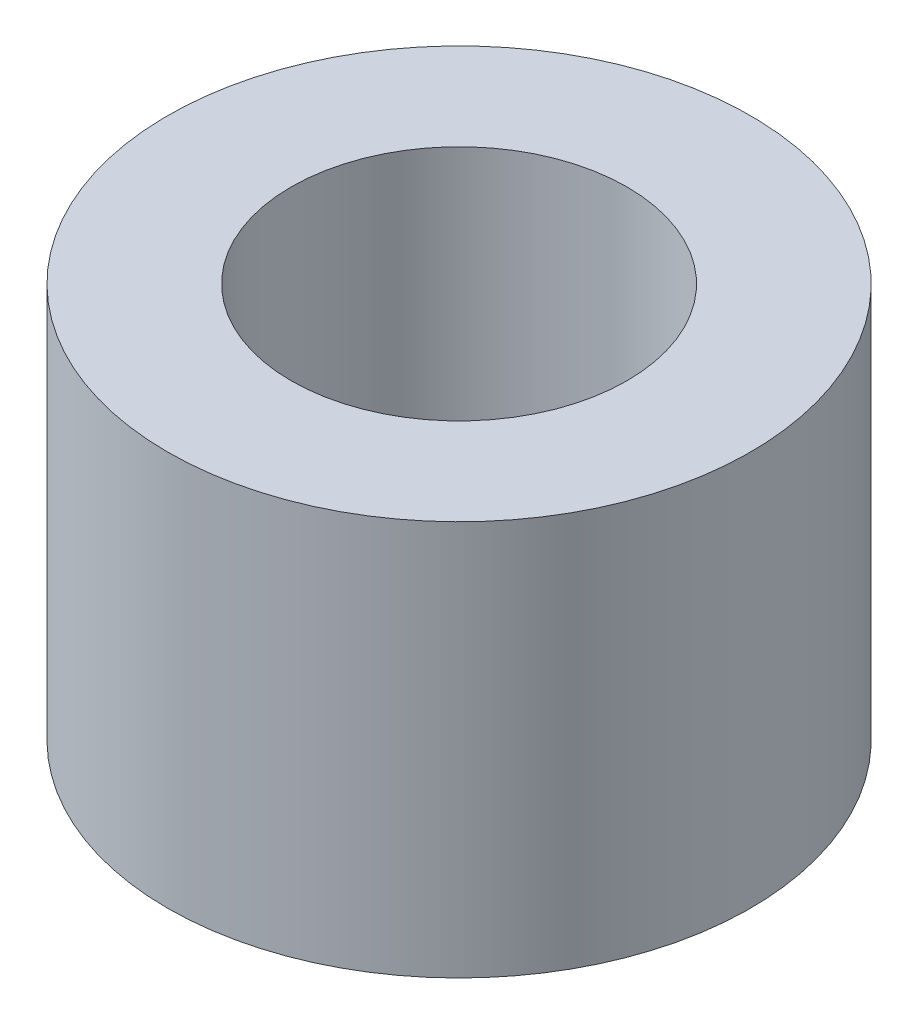
from build123d import *

# Parameters (mm, degrees)
SKETCH2_R           = 2.95
SKETCH2_R_2         = 1.7
BOSS_EXTRUDE1_DEPTH = 4


with BuildPart() as part:
    # Sketch2 → Boss-Extrude1 (new body)
    with BuildSketch(Plane(origin=(0, 0, 0), x_dir=(1, 0, 0), z_dir=(0, 1, 0))):
        Circle(SKETCH2_R)
        Circle(SKETCH2_R_2, mode=Mode.SUBTRACT)
    extrude(amount=BOSS_EXTRUDE1_DEPTH)


solid = part.part
